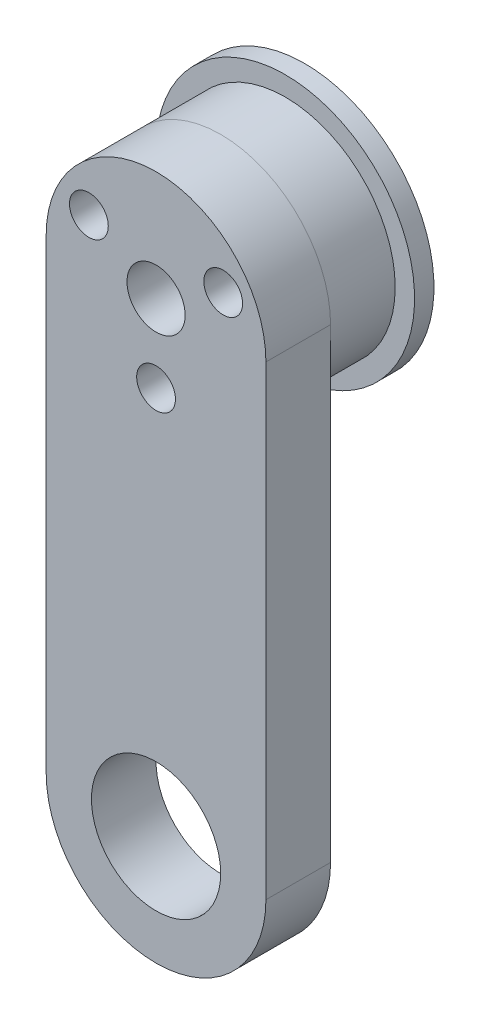
from build123d import *

# Parameters (mm, degrees)
SKETCH_1_R      = 1.5
SKETCH_1_R_2    = 2.25
SKETCH_1_R_3    = 5
EXTRUDE_1_DEPTH = 5
SKETCH_2_R      = 8.5
SKETCH_2_R_2    = 1.5
SKETCH_2_R_3    = 3.35
EXTRUDE_2_DEPTH = 5
SKETCH_3_R      = 10
SKETCH_3_R_2    = 1.5
SKETCH_3_R_3    = 3.35
EXTRUDE_3_DEPTH = 1.5


with BuildPart() as part:
    # 草图1 → 凸台-拉伸1 (new body)
    with BuildSketch(Plane.XY):
        with BuildLine():
            Line((-8.5, -36.02986797), (-8.5, 0))
            ThreePointArc((-8.5, 0), (0, 8.5), (8.5, 0))
            Line((8.5, 0), (8.5, -36.02986797))
            ThreePointArc((8.5, -36.02986797), (0, -44.52986797), (-8.5, -36.02986797))
        make_face()
        with Locations((-5.196152423, 3)):
            Circle(SKETCH_1_R, mode=Mode.SUBTRACT)
        Circle(SKETCH_1_R_2, mode=Mode.SUBTRACT)
        with Locations((0, -36.02986797)):
            Circle(SKETCH_1_R_3, mode=Mode.SUBTRACT)
        with Locations((5.196152423, 3)):
            Circle(SKETCH_1_R, mode=Mode.SUBTRACT)
        with Locations((0, -6)):
            Circle(SKETCH_1_R, mode=Mode.SUBTRACT)
    extrude(amount=EXTRUDE_1_DEPTH)


with BuildPart() as body_2:
    # 草图2 → 凸台-拉伸2 (new body)
    with BuildSketch(Plane(origin=(0, 0, 0), x_dir=(-1, 0, 0), z_dir=(0, 0, -1))):
        Circle(SKETCH_2_R)
        with Locations((0, -6)):
            Circle(SKETCH_2_R_2, mode=Mode.SUBTRACT)
        with Locations((5.196152423, 3)):
            Circle(SKETCH_2_R_2, mode=Mode.SUBTRACT)
        Circle(SKETCH_2_R_3, mode=Mode.SUBTRACT)
        with Locations((-5.196152423, 3)):
            Circle(SKETCH_2_R_2, mode=Mode.SUBTRACT)
    extrude(amount=EXTRUDE_2_DEPTH)


with BuildPart() as body_3:
    # 草图3 → 凸台-拉伸3 (new body)
    with BuildSketch(Plane(origin=(0, 0, -5), x_dir=(-1, 0, 0), z_dir=(0, 0, -1))):
        Circle(SKETCH_3_R)
        with Locations((-5.196152423, 3)):
            Circle(SKETCH_3_R_2, mode=Mode.SUBTRACT)
        Circle(SKETCH_3_R_3, mode=Mode.SUBTRACT)
        with Locations((5.196152423, 3)):
            Circle(SKETCH_3_R_2, mode=Mode.SUBTRACT)
        with Locations((0, -6)):
            Circle(SKETCH_3_R_2, mode=Mode.SUBTRACT)
    extrude(amount=EXTRUDE_3_DEPTH)


solid = Compound([part.part, body_2.part, body_3.part])
